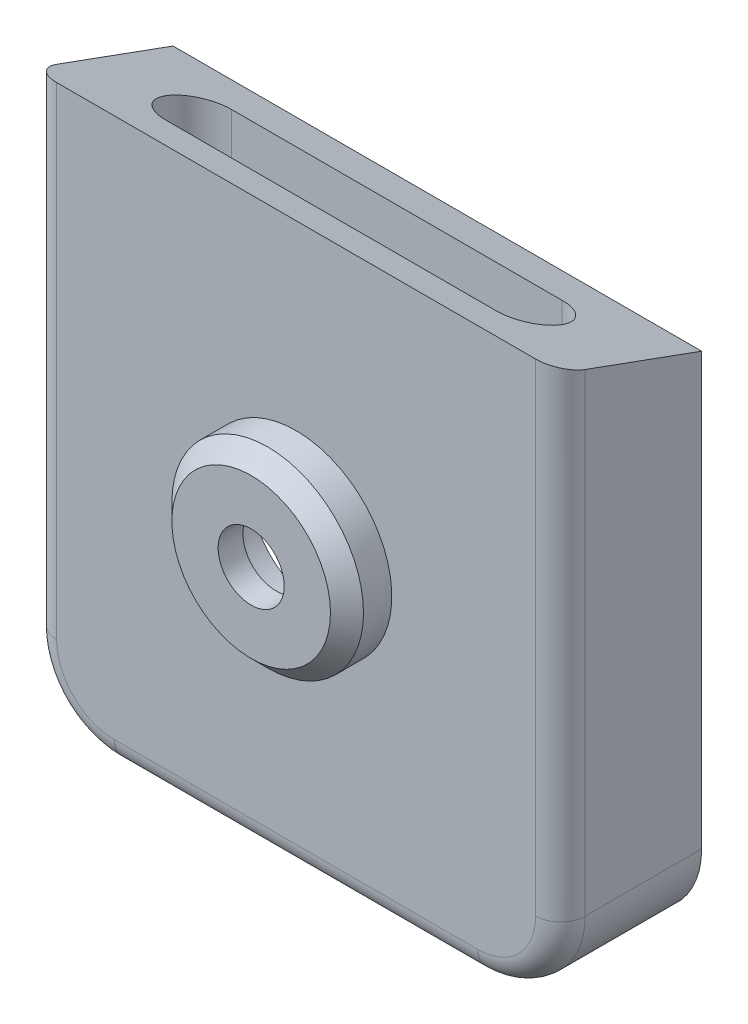
from build123d import *

# Parameters (mm, degrees)
SKETCH1_W           = 32
SKETCH1_H           = 31.091910702798558
BOSS_EXTRUDE1_DEPTH = 1.5
FILLET1_R           = 5
SKETCH2_R           = 4.3000000000159515
CUT_EXTRUDE1_DEPTH  = 45.642545975233084
SKETCH3_R           = 5.79999999998862
SKETCH3_R_2         = 4.299999999994187
BOSS_EXTRUDE2_DEPTH = 1.212999868
SKETCH4_R           = 5.799999999994187
SKETCH4_R_2         = 1.9999999999941904
BOSS_EXTRUDE3_DEPTH = 1.5
CHAMFER1_SIZE       = 1
EXTRUDE_THIN1_DEPTH = 7.05
BOSS_EXTRUDE4_REACH = 47.171
SKETCH7_W           = 29.000000000000004
SKETCH7_H           = 1.8000000000000007
BOSS_EXTRUDE5_DEPTH = 7.05
FILLET2_R           = 2
CUT_EXTRUDE2_DEPTH  = 10
FILLET3_R           = 1.5


with BuildPart() as part:
    # Sketch1 → Boss-Extrude1 (new body)
    with BuildSketch(Plane.XY):
        with Locations((16, 15.545955351399279)):
            Rectangle(SKETCH1_W, SKETCH1_H)
    extrude(amount=BOSS_EXTRUDE1_DEPTH)

    # Fillet1
    fillet1_edges = [part.edges().sort_by_distance(p)[0] for p in [
        (32, 0, 0.75),
        (0, 0, 0.75),
    ]]
    fillet(fillet1_edges, radius=FILLET1_R)

    # Sketch2 → Cut-Extrude1 (cut, through all)
    with BuildSketch(Plane(origin=(0, 0, 0), x_dir=(-1, 0, 0), z_dir=(0, 0, -1))):
        with Locations((-15.991678414180004, 17.403095514898066)):
            Circle(SKETCH2_R)
    extrude(amount=-CUT_EXTRUDE1_DEPTH, mode=Mode.SUBTRACT)

    # Sketch3 → Boss-Extrude2 (add)
    with BuildSketch(Plane.XY.offset(1.5)):
        with Locations(Location((15.991678414180004, 17.403095514898066, 0), (0, 0, 180))):
            Circle(SKETCH3_R)
        with Locations(Location((15.991678414180004, 17.403095514898066, 0), (0, 0, 180))):
            Circle(SKETCH3_R_2, mode=Mode.SUBTRACT)
    extrude(amount=BOSS_EXTRUDE2_DEPTH)

    # Sketch4 → Boss-Extrude3 (add)
    with BuildSketch(Plane.XY.offset(2.7129998678795)):
        with Locations(Location((15.991678414180004, 17.403095514898066, 0), (0, 0, 180))):
            Circle(SKETCH4_R)
        with Locations((15.991678414180004, 17.403095514898066)):
            Circle(SKETCH4_R_2, mode=Mode.SUBTRACT)
    extrude(amount=BOSS_EXTRUDE3_DEPTH)

    # Chamfer1
    chamfer1_edges = [part.edges().sort_by_distance(p)[0] for p in [
        (21.791678414174193, 17.403095514898062, 4.2129998678795),
    ]]
    chamfer(chamfer1_edges, length=CHAMFER1_SIZE)

    # Sketch5 → Extrude-Thin1 (add)
    with BuildSketch(Plane(origin=(0, 0, 0), x_dir=(-1, 0, 0), z_dir=(0, 0, -1))):
        with BuildLine():
            Line((0, 31.091910702798558), (0, 4.999999999999998))
            ThreePointArc((0, 4.999999999999998), (-1.4644660940672622, 1.4644660940672614), (-5, 0))
            Line((-5, 0), (-27, 0))
            ThreePointArc((-27, 0), (-30.535533905932738, 1.4644660940672654), (-32, 4.999999999999998))
            Line((-32, 4.999999999999998), (-32, 31.091910702798558))
            Line((-32, 31.091910702798558), (-30.5, 31.091910702798558))
            Line((-30.5, 31.091910702798558), (-30.5, 4.999999999999998))
            ThreePointArc((-30.5, 4.999999999999996), (-29.47487373415292, 2.5251262658470903), (-27.00000000000001, 1.5000000000000067))
            Line((-27, 1.5), (-5, 1.5))
            ThreePointArc((-4.999999999999999, 1.5), (-2.525126265847083, 2.5251262658470828), (-1.4999999999999996, 4.999999999999998))
            Line((-1.5, 4.999999999999998), (-1.5, 31.091910702798558))
            Line((-1.5, 31.091910702798558), (0, 31.091910702798558))
        make_face()
    extrude(amount=EXTRUDE_THIN1_DEPTH)

    # Boss-Extrude4: up to this face of the body (flat: up to its plane)
    boss_extrude4_end = Plane(part.part.faces().sort_by_distance((0, 18.045955351, -2.775))[0])
    # Sketch6 → Boss-Extrude4 (add, up to the picked face)
    with BuildSketch(Plane(origin=(32, 0, 0), x_dir=(0, 0, -1), z_dir=(1, 0, 0)), mode=Mode.PRIVATE) as boss_extrude4_sk1:
        Polygon((7.050000000000448, 31.09191070279875), (-1.4999999999999993, 34.20385620577456), (-1.5, 31.091910702798558), align=None)
    boss_extrude4_tool1 = split(extrude(boss_extrude4_sk1.sketch, amount=-BOSS_EXTRUDE4_REACH, mode=Mode.PRIVATE), bisect_by=boss_extrude4_end, keep=Keep.BOTH, mode=Mode.PRIVATE)
    add(boss_extrude4_tool1.solids().sort_by(Axis((32, 32.129226, -1.35), (-1, 0, 0)))[0])

    # Sketch7 → Boss-Extrude5 (add)
    with BuildSketch(Plane(origin=(0, 0, 0), x_dir=(-1, 0, 0), z_dir=(0, 0, -1))):
        with Locations((-16, 30.19191070279856)):
            Rectangle(SKETCH7_W, SKETCH7_H)
    extrude(amount=BOSS_EXTRUDE5_DEPTH)

    # Fillet2
    fillet2_edges = [part.edges().sort_by_distance(p)[0] for p in [
        (30.5, 29.291910702798557, -3.525),
        (1.5, 29.291910702798557, -3.525),
    ]]
    fillet(fillet2_edges, radius=FILLET2_R)

    # Sketch8 → Cut-Extrude2 (cut)
    with BuildSketch(Plane.XZ.offset(-29.291910702798557)):
        with BuildLine():
            Line((26, -4.600000000000001), (6.000000000000002, -4.600000000000004))
            ThreePointArc((6.000000000000002, -4.600000000000004), (3.9999999999999996, -2.600000000000004), (6.000000000000001, -0.6000000000000024))
            Line((6.000000000000001, -0.6000000000000024), (26, -0.6))
            ThreePointArc((26, -0.6), (28, -2.600000000000002), (26, -4.600000000000001))
        make_face()
    extrude(amount=-CUT_EXTRUDE2_DEPTH, mode=Mode.SUBTRACT)

    # Fillet3
    fillet3_edges = [part.edges().sort_by_distance(p)[0] for p in [
        (32, 19.60192810288728, 1.4999999999999996),
        (16, 0, 1.5),
        (1.4644660940672618, 1.4644660940672614, 1.5),
        (30.535533905932738, 1.4644660940672618, 1.5),
        (-4.4e-16, 19.60192810288728, 1.4999999999999996),
    ]]
    fillet(fillet3_edges, radius=FILLET3_R)


solid = part.part
